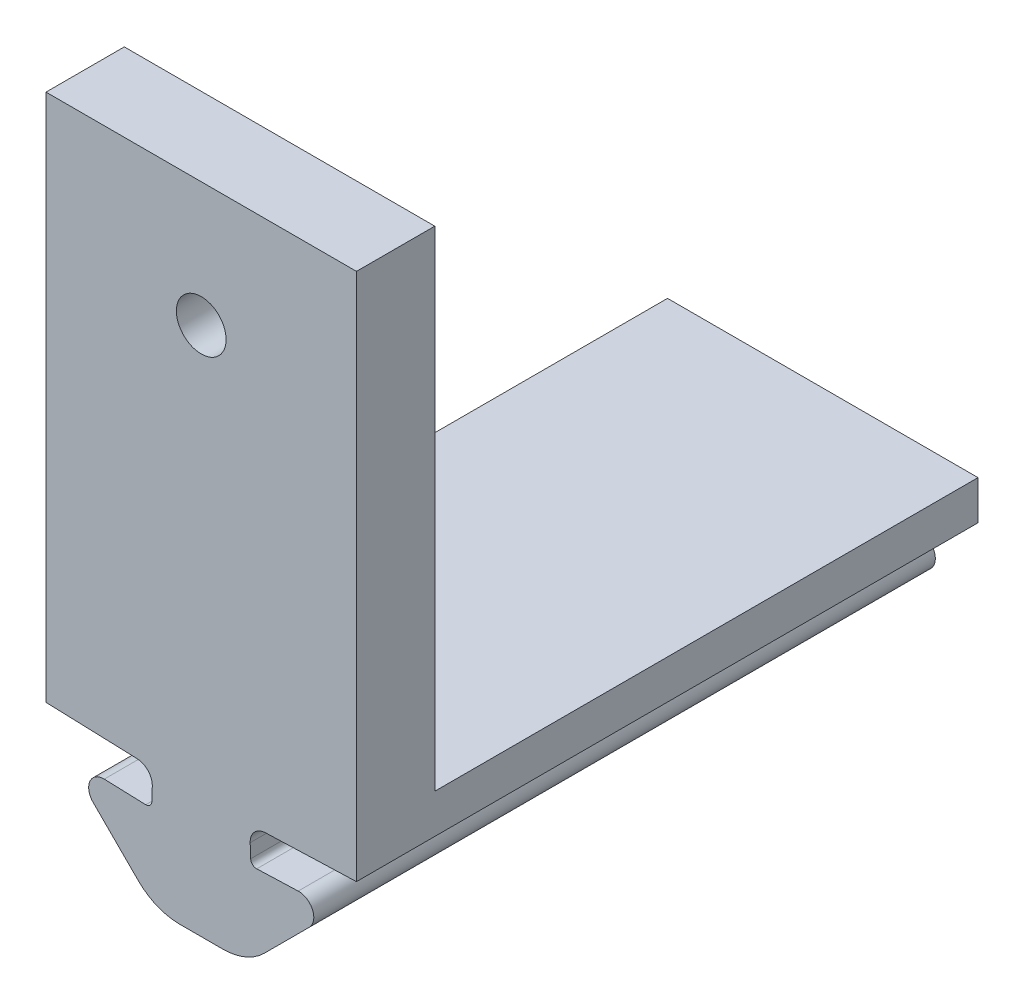
from build123d import *

# Parameters (mm, degrees)
BOSS_EXTRUDE1_DEPTH = 31.75
SKETCH19_W          = 15.860402013
SKETCH19_H          = 31.75
BOSS_EXTRUDE7_DEPTH = 2
SKETCH23_W          = 15.860402013
SKETCH23_H          = 4
BOSS_EXTRUDE8_DEPTH = 25
SKETCH24_R          = 1.27
CUT_EXTRUDE1_DEPTH  = 5


with BuildPart() as part:
    # Sketch2 → Boss-Extrude1 (new body)
    with BuildSketch(Plane.XY):
        with BuildLine():
            Line((-50.375618534, 45.609862895), (-50.351188886, 46.309436474))
            ThreePointArc((-50.351188886, 46.309436474), (-50.565618587, 46.88295476), (-51.12278195, 47.136868733))
            Line((-51.12278195, 47.136868733), (-55.780902554, 47.299533889))
            Line((-55.780902554, 47.299533889), (-47.850701548, 47.299533889))
            Line((-47.850701548, 47.299533889), (-47.850701548, 40.900752235))
            Line((-47.850701548, 40.900752235), (-48.952946324, 40.900752235))
            ThreePointArc((-48.952946324, 40.900752235), (-50.100996621, 41.129113637), (-51.074266668, 41.779431891))
            Line((-51.074266668, 41.779431891), (-53.375146928, 44.080312152))
            ThreePointArc((-53.375146928, 44.080312152), (-53.536830204, 44.931922499), (-52.803734096, 45.394471696))
            Line((-52.803734096, 45.394471696), (-50.685905631, 45.320515496))
            ThreePointArc((-50.685905631, 45.320515496), (-50.470836274, 45.400926634), (-50.375618534, 45.609862895))
        make_face()
    boss_extrude1 = extrude(amount=BOSS_EXTRUDE1_DEPTH)

    # Mirror2: Boss-Extrude1 across plane
    add(boss_extrude1.mirror(Plane(origin=(-47.850701548, 40.900752235, 31.75), x_dir=(0, 0, 1), z_dir=(-1, 0, 0))))

    # Sketch19 → Boss-Extrude7 (add)
    with BuildSketch(Plane(origin=(0, 47.299533889, 0), x_dir=(1, 0, 0), z_dir=(0, 1, 0))):
        with Locations((-47.850701548, -15.875)):
            Rectangle(SKETCH19_W, SKETCH19_H)
    extrude(amount=BOSS_EXTRUDE7_DEPTH)

    # Sketch23 → Boss-Extrude8 (add)
    with BuildSketch(Plane(origin=(0, 49.299533889, 0), x_dir=(1, 0, 0), z_dir=(0, 1, 0))):
        with Locations((-47.850701548, -29.75)):
            Rectangle(SKETCH23_W, SKETCH23_H)
    extrude(amount=BOSS_EXTRUDE8_DEPTH)

    # Sketch24 → Cut-Extrude1 (cut, through all)
    with BuildSketch(Plane(origin=(0, 0, 27.75), x_dir=(-1, 0, 0), z_dir=(0, 0, -1))):
        with Locations((47.850701548, 67.949533889)):
            Circle(SKETCH24_R)
    extrude(amount=-CUT_EXTRUDE1_DEPTH, mode=Mode.SUBTRACT)


solid = part.part
